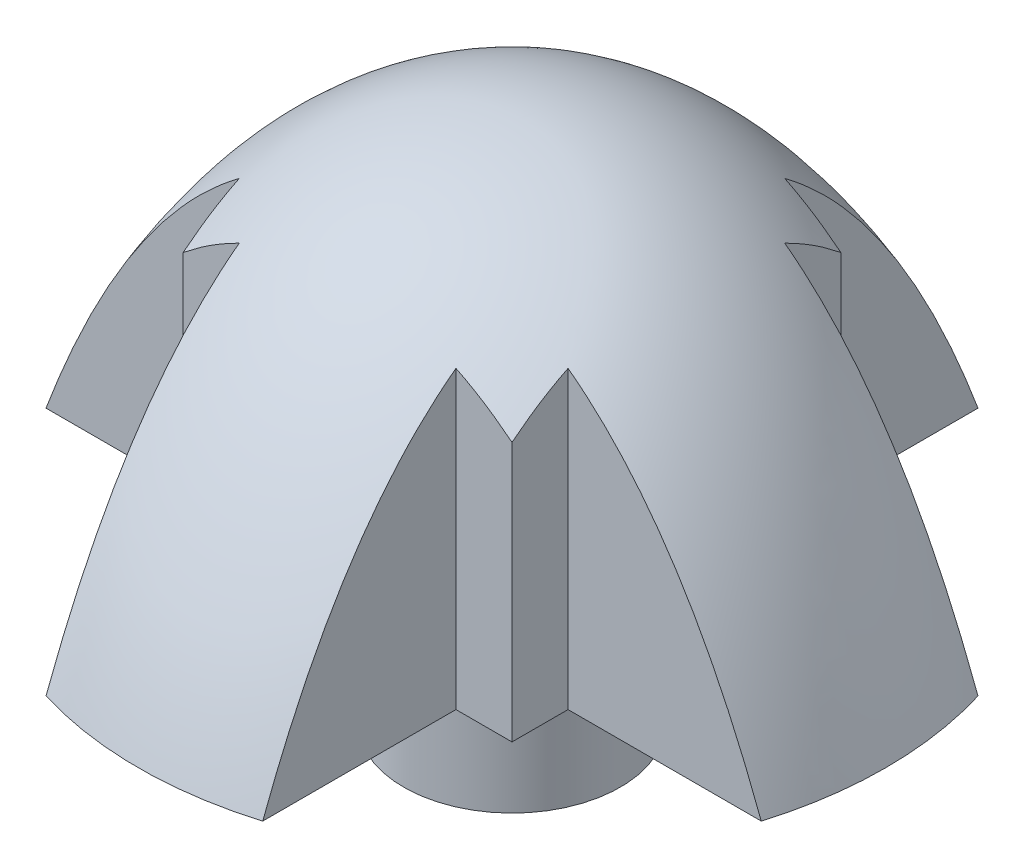
from build123d import *

# Parameters (mm, degrees)
SKETCH3_W          = 1.45
SKETCH3_H          = 2
CUT_EXTRUDE1_REACH = 7


with BuildPart() as part:
    # Sketch3 → Revolve1 (revolve)
    with BuildSketch(Plane.XY):
        with BuildLine():
            add(Edge.make_bspline(
                [(5, 0), (3.201562119, 5), (0, 5)],
                knots=[0, 0, 0, 1, 1, 1], degree=2))
            Line((0, 5), (0, 0.5))
            Line((0, 0.5), (0, 0))
            Line((0, 0), (1.45, 0))
            Line((1.45, 0), (2.5, 0))
            Line((2.5, 0), (5, 0))
        make_face()
        with BuildLine():
            add(Edge.make_bspline(
                [(5, 0), (3.201562119, 5), (0, 5)],
                knots=[0, 0, 0, 1, 1, 1], degree=2))
            Line((0, 5), (0, 0.5))
            Line((0, 0.5), (0, 0))
            Line((0, 0), (1.45, 0))
            Line((1.45, 0), (2.5, 0))
            Line((2.5, 0), (5, 0))
        make_face()
        with Locations((0.725, -1)):
            Rectangle(SKETCH3_W, SKETCH3_H)
    revolve(axis=Axis((0, 5, 0), (0, -1, 0)))

    # Sketch5 → Cut-Extrude1 (cut, up to next)
    with BuildSketch(Plane.XZ, mode=Mode.PRIVATE) as cut_extrude1_sk1:
        with BuildLine():
            Line((-2.2, 2.2), (-1.45, 2.2))
            Line((-1.45, 2.2), (-1.45, 4.785133227))
            ThreePointArc((-1.45, 4.785133227), (-3.535533906, 3.535533906), (-4.785133227, 1.45))
            Line((-4.785133227, 1.45), (-2.2, 1.45))
            Line((-2.2, 1.45), (-2.2, 2.2))
        make_face()
    cut_extrude1_tool1 = extrude(cut_extrude1_sk1.sketch, amount=-CUT_EXTRUDE1_REACH, mode=Mode.PRIVATE) & part.part
    add(cut_extrude1_tool1.solids().sort_by_distance((-2.819915, 0, 2.819915))[0], mode=Mode.SUBTRACT)
    # Sketch5 → Cut-Extrude1 (cut, up to next)
    with BuildSketch(Plane.XZ, mode=Mode.PRIVATE) as cut_extrude1_sk2:
        with BuildLine():
            Line((1.45, 2.2), (2.2, 2.2))
            Line((2.2, 2.2), (2.2, 1.45))
            Line((2.2, 1.45), (4.785133227, 1.45))
            ThreePointArc((4.785133227, 1.45), (3.535533906, 3.535533906), (1.45, 4.785133227))
            Line((1.45, 4.785133227), (1.45, 2.2))
        make_face()
    cut_extrude1_tool2 = extrude(cut_extrude1_sk2.sketch, amount=-CUT_EXTRUDE1_REACH, mode=Mode.PRIVATE) & part.part
    add(cut_extrude1_tool2.solids().sort_by_distance((2.819915, 0, 2.819915))[0], mode=Mode.SUBTRACT)
    # Sketch5 → Cut-Extrude1 (cut, up to next)
    with BuildSketch(Plane.XZ, mode=Mode.PRIVATE) as cut_extrude1_sk3:
        with BuildLine():
            Line((4.785133227, -1.45), (2.2, -1.45))
            Line((2.2, -1.45), (2.2, -2.2))
            Line((2.2, -2.2), (1.45, -2.2))
            Line((1.45, -2.2), (1.45, -4.785133227))
            ThreePointArc((1.45, -4.785133227), (3.535533906, -3.535533906), (4.785133227, -1.45))
        make_face()
    cut_extrude1_tool3 = extrude(cut_extrude1_sk3.sketch, amount=-CUT_EXTRUDE1_REACH, mode=Mode.PRIVATE) & part.part
    add(cut_extrude1_tool3.solids().sort_by_distance((2.819915, 0, -2.819915))[0], mode=Mode.SUBTRACT)
    # Sketch5 → Cut-Extrude1 (cut, up to next)
    with BuildSketch(Plane.XZ, mode=Mode.PRIVATE) as cut_extrude1_sk4:
        with BuildLine():
            Line((-2.2, -2.2), (-2.2, -1.45))
            Line((-2.2, -1.45), (-4.785133227, -1.45))
            ThreePointArc((-4.785133227, -1.45), (-3.535533906, -3.535533906), (-1.45, -4.785133227))
            Line((-1.45, -4.785133227), (-1.45, -2.2))
            Line((-1.45, -2.2), (-2.2, -2.2))
        make_face()
    cut_extrude1_tool4 = extrude(cut_extrude1_sk4.sketch, amount=-CUT_EXTRUDE1_REACH, mode=Mode.PRIVATE) & part.part
    add(cut_extrude1_tool4.solids().sort_by_distance((-2.819915, 0, -2.819915))[0], mode=Mode.SUBTRACT)


solid = part.part
